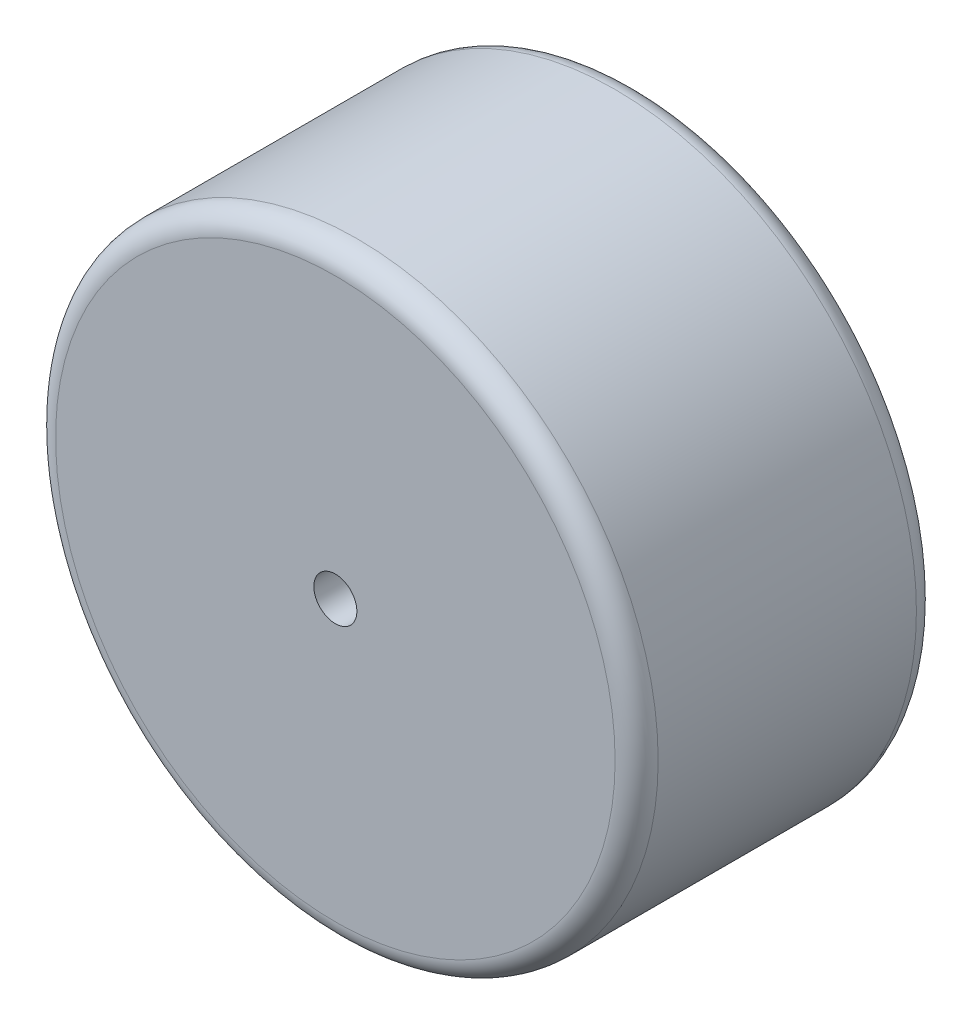
from build123d import *

# Parameters (mm, degrees)
SKETCH1_R           = 88.9
SKETCH1_R_2         = 6.35
BOSS_EXTRUDE1_DEPTH = 88.9
FILLET1_R           = 6.35


with BuildPart() as part:
    # Sketch1 → Boss-Extrude1 (new body)
    with BuildSketch(Plane.XY):
        Circle(SKETCH1_R)
        Circle(SKETCH1_R_2, mode=Mode.SUBTRACT)
    extrude(amount=BOSS_EXTRUDE1_DEPTH)

    # Fillet1
    fillet1_edges = [part.edges().sort_by_distance(p)[0] for p in [
        (-88.9, 0, 0),
        (-88.9, 0, 88.9),
    ]]
    fillet(fillet1_edges, radius=FILLET1_R)


solid = part.part
